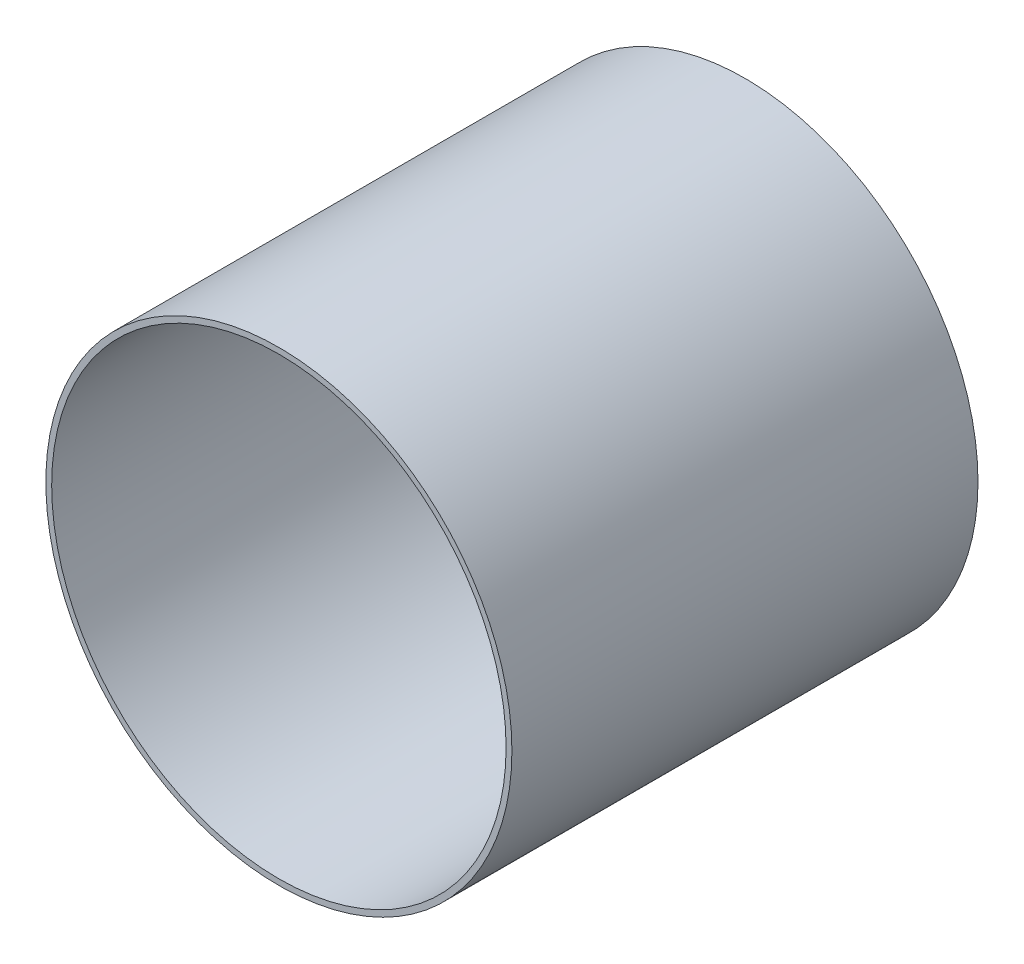
from build123d import *

# Parameters (mm, degrees)
ESQUISSE1_R        = 20
ESQUISSE1_R_2      = 19.5
BOSS_EXTRU_1_DEPTH = 40


with BuildPart() as part:
    # Esquisse1 → Boss.-Extru.1 (new body)
    with BuildSketch(Plane.XY):
        Circle(ESQUISSE1_R)
        Circle(ESQUISSE1_R_2, mode=Mode.SUBTRACT)
    extrude(amount=BOSS_EXTRU_1_DEPTH)


solid = part.part
